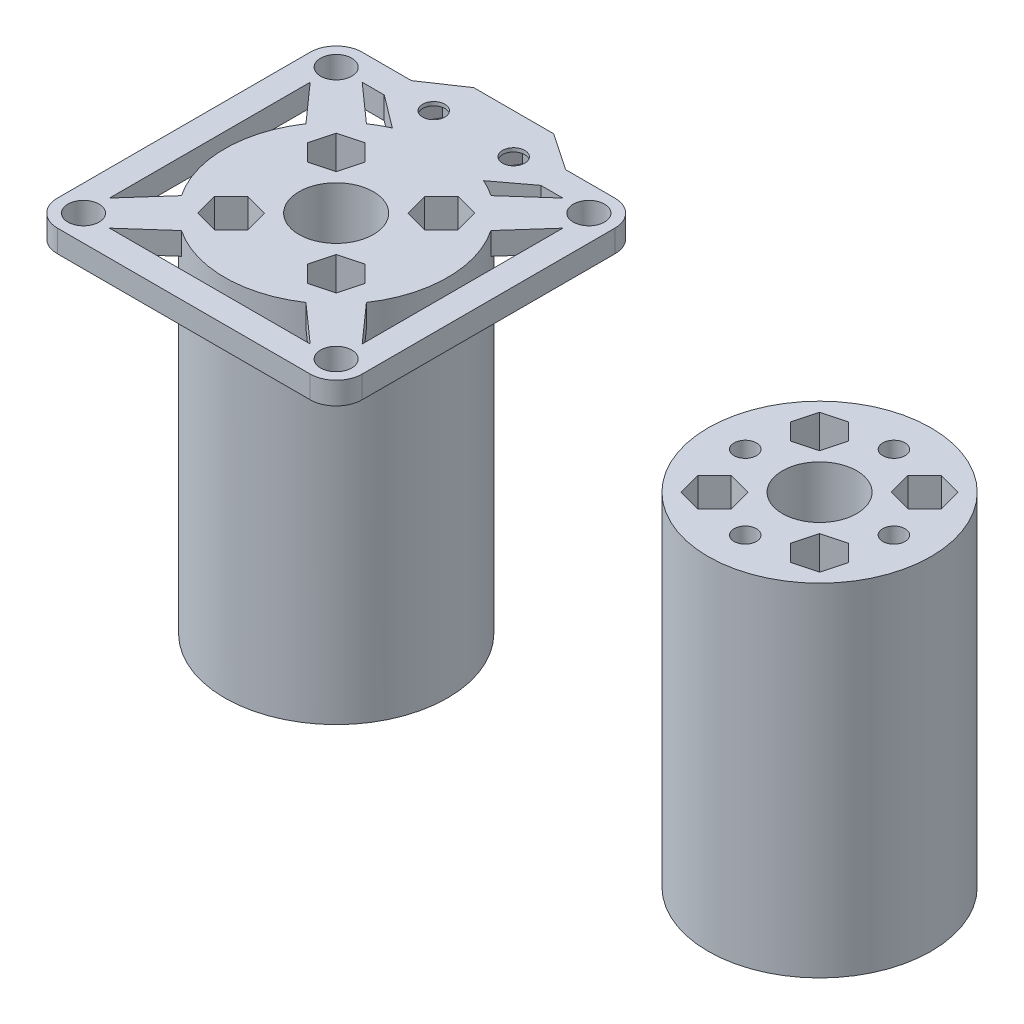
from build123d import *

# Parameters (mm, degrees)
SKETCH_1_R               = 15
SKETCH_1_R_2             = 5
EXTRUDE_4_DEPTH          = 3
SKETCH_1_R_3             = 3.5
SKETCH_1_R_4             = 2.1
EXTRUDE_4_2_DEPTH        = 3
EXTRUDE_5_DEPTH          = 3
PATTERN_CIRCULAR_2_COUNT = 4
SKETCH_6_R               = 3.5
SKETCH_6_R_2             = 2.1
EXTRUDE_6_DEPTH          = 3
PATTERN_CIRCULAR_3_COUNT = 4
SKETCH_7_R               = 15
SKETCH_7_R_2             = 5
EXTRUDE_7_DEPTH          = 46
CUT_EXTRUDE_1_DEPTH      = 46
PATTERN_CIRCULAR_4_COUNT = 4
SKETCH_11_R              = 1.5
CUT_EXTRUDE_2_DEPTH      = 3
PATTERN_CIRCULAR_5_COUNT = 4
EXTRUDE_8_DEPTH          = 3
EXTRUDE_9_DEPTH          = 3
EXTRUDE_10_DEPTH         = 3
EXTRUDE_11_DEPTH         = 3
EXTRUDE_13_DEPTH         = 3
EXTRUDE_14_DEPTH         = 3
CUT_EXTRUDE_3_DEPTH      = 2.5
SKETCH_19_R              = 1.5
CUT_EXTRUDE_4_DEPTH      = 2.5
SKETCH_20_R              = 1.5
CUT_EXTRUDE_5_DEPTH      = 2.5
SKETCH_21_R              = 15
SKETCH_21_R_2            = 5
EXTRUDE_15_DEPTH         = 3
SKETCH_22_R              = 1.5
CUT_EXTRUDE_6_DEPTH      = 3
PATTERN_CIRCULAR_6_COUNT = 4
EXTRUDE_16_DEPTH         = 3
CUT_EXTRUDE_7_DEPTH      = 3
SKETCH_25_R              = 15
SKETCH_25_R_2            = 5
EXTRUDE_17_DEPTH         = 43
SKETCH_27_R              = 1.5
CUT_EXTRUDE_8_DEPTH      = 46
SKETCH_28_R              = 2.75
CUT_EXTRUDE_9_DEPTH      = 43
SKETCH_29_R              = 1.5
CUT_EXTRUDE_10_DEPTH     = 46
PATTERN_CIRCULAR_7_COUNT = 4
CUT_EXTRUDE_11_DEPTH     = 43
PATTERN_CIRCULAR_8_COUNT = 4


with BuildPart() as part:
    # 草图1 → 凸台-拉伸4 (new body)
    with BuildSketch(Plane(origin=(0, 0, 0), x_dir=(1, 0, 0), z_dir=(0, 1, 0))):
        with Locations((-5.372895461, -8.931727747)):
            Circle(SKETCH_1_R)
        with Locations((-5.372895461, -8.931727747)):
            Circle(SKETCH_1_R_2, mode=Mode.SUBTRACT)
    extrude(amount=EXTRUDE_4_DEPTH)



with BuildPart() as body_2:
    # 草图1 → Extrude 4 2 (new body)
    with BuildSketch(Plane(origin=(0, 0, 0), x_dir=(1, 0, 0), z_dir=(0, 1, 0))):
        with Locations((-22.372895461, 8.068272253)):
            Circle(SKETCH_1_R_3)
        with Locations((-22.372895461, 8.068272253)):
            Circle(SKETCH_1_R_4, mode=Mode.SUBTRACT)
    extrude(amount=EXTRUDE_4_2_DEPTH)


with BuildPart() as part_1:
    add(part.part)

    add(body_2.part)  # 凸台-拉伸5 merges body 2
    # 草图5 → 凸台-拉伸5 (add)
    with BuildSketch(Plane(origin=(0, 0, 0), x_dir=(1, 0, 0), z_dir=(0, 1, 0))):
        Polygon((-22.372895461, 4.568272253), (-10.372895461, -8.931727747), (-10.372895461, -3.931727747), (-5.372895461, -3.931727747), (-18.872895461, 8.068272253), align=None)
    extrude_5 = extrude(amount=EXTRUDE_5_DEPTH)

    # 阵列(圆周)2: 凸台-拉伸5 ×4 about axis
    pattern_circular_2_axis = Axis((-5.372895461, 0, 8.931727747), (0, 1, 0))
    for i in range(1, PATTERN_CIRCULAR_2_COUNT):
        add(extrude_5.rotate(pattern_circular_2_axis, i * 360 / PATTERN_CIRCULAR_2_COUNT))

    # 草图6 → 凸台-拉伸6 (add)
    with BuildSketch(Plane(origin=(0, 3, 0), x_dir=(1, 0, 0), z_dir=(0, 1, 0))):
        with Locations((11.627104539, 8.068272253)):
            Circle(SKETCH_6_R)
        with Locations((11.627104539, 8.068272253)):
            Circle(SKETCH_6_R_2, mode=Mode.SUBTRACT)
    extrude_6 = extrude(amount=-EXTRUDE_6_DEPTH)

    # 阵列(圆周)3: 凸台-拉伸6 ×4 about axis
    pattern_circular_3_axis = Axis((-5.372895461, 0, 8.931727747), (0, 1, 0))
    for i in range(1, PATTERN_CIRCULAR_3_COUNT):
        add(extrude_6.rotate(pattern_circular_3_axis, i * 360 / PATTERN_CIRCULAR_3_COUNT))

    # 草图7 → 凸台-拉伸7 (add)
    with BuildSketch(Plane.XZ):
        with Locations((-5.372895461, 8.931727747)):
            Circle(SKETCH_7_R)
        with Locations((-5.372895461, 8.931727747)):
            Circle(SKETCH_7_R_2, mode=Mode.SUBTRACT)
    extrude(amount=EXTRUDE_7_DEPTH)

    # 草图9 → 切除-拉伸1 (cut)
    with BuildSketch(Plane(origin=(0, 3, 0), x_dir=(1, 0, 0), z_dir=(0, 1, 0))):
        Polygon((0.876311502, -19.070022006), (-1.369054096, -16.824656408), (-0.547193246, -13.757429961), (2.520033201, -12.935569112), (4.765398798, -15.180934709), (3.943537949, -18.248161156), align=None)
    cut_extrude_1 = extrude(amount=-CUT_EXTRUDE_1_DEPTH, mode=Mode.SUBTRACT)

    # 阵列(圆周)4: 切除-拉伸1 ×4 about axis
    pattern_circular_4_axis = Axis((-5.372895461, 0, 8.931727747), (0, 1, 0))
    for i in range(1, PATTERN_CIRCULAR_4_COUNT):
        add(cut_extrude_1.rotate(pattern_circular_4_axis, i * 360 / PATTERN_CIRCULAR_4_COUNT), mode=Mode.SUBTRACT)

    # 草图11 → 切除-拉伸2 (cut)
    with BuildSketch(Plane(origin=(0, -43, 0), x_dir=(1, 0, 0), z_dir=(0, 1, 0))):
        with Locations((1.698172351, -1.860659935)):
            Circle(SKETCH_11_R)
    cut_extrude_2 = extrude(amount=-CUT_EXTRUDE_2_DEPTH, mode=Mode.SUBTRACT)

    # 阵列(圆周)5: 切除-拉伸2 ×4 about axis
    pattern_circular_5_axis = Axis((-5.372895461, 0, 8.931727747), (0, 1, 0))
    for i in range(1, PATTERN_CIRCULAR_5_COUNT):
        add(cut_extrude_2.rotate(pattern_circular_5_axis, i * 360 / PATTERN_CIRCULAR_5_COUNT), mode=Mode.SUBTRACT)

    # 草图12 → 凸台-拉伸8 (add)
    with BuildSketch(Plane(origin=(0, 3, 0), x_dir=(1, 0, 0), z_dir=(0, 1, 0))):
        Polygon((15.127104539, 8.068272253), (15.127104539, -25.931727747), (11.627104539, -22.431727747), (11.627104539, 4.568272253), align=None)
    extrude(amount=-EXTRUDE_8_DEPTH)

    # 草图13 → 凸台-拉伸9 (add)
    with BuildSketch(Plane(origin=(0, 3, 0), x_dir=(1, 0, 0), z_dir=(0, 1, 0))):
        Polygon((11.627104539, 11.568272253), (-22.372895461, 11.568272253), (-18.872895461, 8.068272253), (8.127104539, 8.068272253), align=None)
    extrude(amount=-EXTRUDE_9_DEPTH)

    # 草图14 → 凸台-拉伸10 (add)
    with BuildSketch(Plane(origin=(0, 3, 0), x_dir=(1, 0, 0), z_dir=(0, 1, 0))):
        Polygon((-25.872895461, 8.068272253), (-25.872895461, -25.931727747), (-22.372895461, -22.431727747), (-22.372895461, 4.568272253), align=None)
    extrude(amount=-EXTRUDE_10_DEPTH)

    # 草图15 → 凸台-拉伸11 (add)
    with BuildSketch(Plane(origin=(0, 3, 0), x_dir=(1, 0, 0), z_dir=(0, 1, 0))):
        Polygon((-22.372895461, -29.431727747), (11.627104539, -29.431727747), (8.127104539, -25.931727747), (-18.872895461, -25.931727747), align=None)
    extrude(amount=-EXTRUDE_11_DEPTH)

    # 草图16 → 凸台-拉伸13 (add)
    with BuildSketch(Plane.XZ):
        Polygon((-10.747895461, -4.193272253), (0.002104539, -4.193272253), (5.163560245, -8.068272253), (4.99115505, -11.568272253), (0.002104539, -14.943272253), (-10.747895461, -14.943272253), (-15.736945971, -11.568272253), (-15.909351166, -8.068272253), align=None)
        Polygon((-7.57246898, -9.568272253), (-9.16018222, -6.818272253), (-12.335608701, -6.818272253), (-13.923321941, -9.568272253), (-12.335608701, -12.318272253), (-9.16018222, -12.318272253), align=None, mode=Mode.SUBTRACT)
        Polygon((3.17753102, -9.568272253), (1.58981778, -6.818272253), (-1.585608701, -6.818272253), (-3.173321941, -9.568272253), (-1.585608701, -12.318272253), (1.58981778, -12.318272253), align=None, mode=Mode.SUBTRACT)
    extrude(amount=-EXTRUDE_13_DEPTH)

    # 草图18 → 凸台-拉伸14 (add)
    with BuildSketch(Plane.XZ):
        Polygon((-7.57246898, -9.568272253), (-9.16018222, -6.818272253), (-12.335608701, -6.818272253), (-13.923321941, -9.568272253), (-12.335608701, -12.318272253), (-9.16018222, -12.318272253), align=None)
        Polygon((3.17753102, -9.568272253), (1.58981778, -6.818272253), (-1.585608701, -6.818272253), (-3.173321941, -9.568272253), (-1.585608701, -12.318272253), (1.58981778, -12.318272253), align=None)
    extrude(amount=-EXTRUDE_14_DEPTH)

    # 草图17 → 切除-拉伸3 (cut)
    with BuildSketch(Plane.XZ):
        Polygon((-7.57246898, -9.568272253), (-9.16018222, -6.818272253), (-12.335608701, -6.818272253), (-13.923321941, -9.568272253), (-12.335608701, -12.318272253), (-9.16018222, -12.318272253), align=None)
        Polygon((3.17753102, -9.568272253), (1.58981778, -6.818272253), (-1.585608701, -6.818272253), (-3.173321941, -9.568272253), (-1.585608701, -12.318272253), (1.58981778, -12.318272253), align=None)
    extrude(amount=-CUT_EXTRUDE_3_DEPTH, mode=Mode.SUBTRACT)

    # 草图19 → 切除-拉伸4 (cut)
    with BuildSketch(Plane.XZ.offset(-2.5)):
        with Locations((0.002104539, -9.568272253)):
            Circle(SKETCH_19_R)
    extrude(amount=-CUT_EXTRUDE_4_DEPTH, mode=Mode.SUBTRACT)

    # 草图20 → 切除-拉伸5 (cut)
    with BuildSketch(Plane.XZ.offset(-2.5)):
        with Locations((-10.747895461, -9.568272253)):
            Circle(SKETCH_20_R)
    extrude(amount=-CUT_EXTRUDE_5_DEPTH, mode=Mode.SUBTRACT)

    # 草图8 → 凸台-拉伸16 (add)
    with BuildSketch(Plane.XZ.offset(46)):
        Polygon((3.943537949, 18.248161156), (0.876311502, 19.070022006), (-1.369054096, 16.824656408), (-0.547193246, 13.757429961), (2.520033201, 12.935569112), (4.765398798, 15.180934709), align=None)
    extrude(amount=EXTRUDE_16_DEPTH)

    # 草图24 → 切除-拉伸7 (cut)
    with BuildSketch(Plane.XZ.offset(49)):
        Polygon((4.765398798, 15.180934709), (3.943537949, 18.248161156), (0.876311502, 19.070022006), (-1.369054096, 16.824656408), (-0.547193246, 13.757429961), (2.520033201, 12.935569112), align=None)
    extrude(amount=-CUT_EXTRUDE_7_DEPTH, mode=Mode.SUBTRACT)


with BuildPart() as body_2_2:
    # 草图21 → 凸台-拉伸15 (new body)
    with BuildSketch(Plane(origin=(0, 0, 0), x_dir=(1, 0, 0), z_dir=(0, 1, 0))):
        with Locations((59.665545214, -8.931727747)):
            Circle(SKETCH_21_R)
        with Locations((59.665545214, -8.931727747)):
            Circle(SKETCH_21_R_2, mode=Mode.SUBTRACT)
    extrude(amount=EXTRUDE_15_DEPTH)

    # 草图22 → 切除-拉伸6 (cut)
    with BuildSketch(Plane.XZ):
        with Locations((59.665545214, 18.931727747)):
            Circle(SKETCH_22_R)
    cut_extrude_6 = extrude(amount=-CUT_EXTRUDE_6_DEPTH, mode=Mode.SUBTRACT)

    # 阵列(圆周)6: 切除-拉伸6 ×4 about axis
    pattern_circular_6_axis = Axis((59.665545214, 0, 8.931727747), (0, 1, 0))
    for i in range(1, PATTERN_CIRCULAR_6_COUNT):
        add(cut_extrude_6.rotate(pattern_circular_6_axis, i * 360 / PATTERN_CIRCULAR_6_COUNT), mode=Mode.SUBTRACT)

    # 草图25 → 凸台-拉伸17 (add)
    with BuildSketch(Plane.XZ):
        with Locations((59.665545214, 8.931727747)):
            Circle(SKETCH_25_R)
        with Locations((59.665545214, 8.931727747)):
            Circle(SKETCH_25_R_2, mode=Mode.SUBTRACT)
    extrude(amount=EXTRUDE_17_DEPTH)

    # 草图27 → 切除-拉伸8 (cut)
    with BuildSketch(Plane(origin=(0, 3, 0), x_dir=(1, 0, 0), z_dir=(0, 1, 0))):
        with Locations((59.665545214, 1.068272253)):
            Circle(SKETCH_27_R)
        with Locations((69.665545214, -8.931727747)):
            Circle(SKETCH_27_R)
        with Locations((59.665545214, -18.931727747)):
            Circle(SKETCH_27_R)
        with Locations((49.665545214, -8.931727747)):
            Circle(SKETCH_27_R)
    extrude(amount=-CUT_EXTRUDE_8_DEPTH, mode=Mode.SUBTRACT)

    # 草图28 → 切除-拉伸9 (cut)
    with BuildSketch(Plane.XZ.offset(43)):
        with Locations((59.665545214, 18.931727747)):
            Circle(SKETCH_28_R)
        with Locations((49.665545214, 8.931727747)):
            Circle(SKETCH_28_R)
        with Locations((59.665545214, -1.068272253)):
            Circle(SKETCH_28_R)
        with Locations((69.665545214, 8.931727747)):
            Circle(SKETCH_28_R)
    extrude(amount=-CUT_EXTRUDE_9_DEPTH, mode=Mode.SUBTRACT)

    # 草图29 → 切除-拉伸10 (cut)
    with BuildSketch(Plane(origin=(0, 3, 0), x_dir=(1, 0, 0), z_dir=(0, 1, 0))):
        with Locations((66.736613026, -1.860659935)):
            Circle(SKETCH_29_R)
    cut_extrude_10 = extrude(amount=-CUT_EXTRUDE_10_DEPTH, mode=Mode.SUBTRACT)

    # 阵列(圆周)7: 切除-拉伸10 ×4 about axis
    pattern_circular_7_axis = Axis((59.665545214, 0, 8.931727747), (0, 1, 0))
    for i in range(1, PATTERN_CIRCULAR_7_COUNT):
        add(cut_extrude_10.rotate(pattern_circular_7_axis, i * 360 / PATTERN_CIRCULAR_7_COUNT), mode=Mode.SUBTRACT)

    # 草图30 → 切除-拉伸11 (cut)
    with BuildSketch(Plane(origin=(0, 3, 0), x_dir=(1, 0, 0), z_dir=(0, 1, 0))):
        Polygon((64.491247429, -4.106025533), (67.558473876, -4.927886382), (69.803839473, -2.682520785), (68.981978624, 0.384705662), (65.914752177, 1.206566512), (63.669386579, -1.038799086), align=None)
    cut_extrude_11 = extrude(amount=-CUT_EXTRUDE_11_DEPTH, mode=Mode.SUBTRACT)

    # 阵列(圆周)8: 切除-拉伸11 ×4 about axis
    pattern_circular_8_axis = Axis((59.665545214, 0, 8.931727747), (0, 1, 0))
    for i in range(1, PATTERN_CIRCULAR_8_COUNT):
        add(cut_extrude_11.rotate(pattern_circular_8_axis, i * 360 / PATTERN_CIRCULAR_8_COUNT), mode=Mode.SUBTRACT)


solid = Compound([part_1.part, body_2_2.part])
